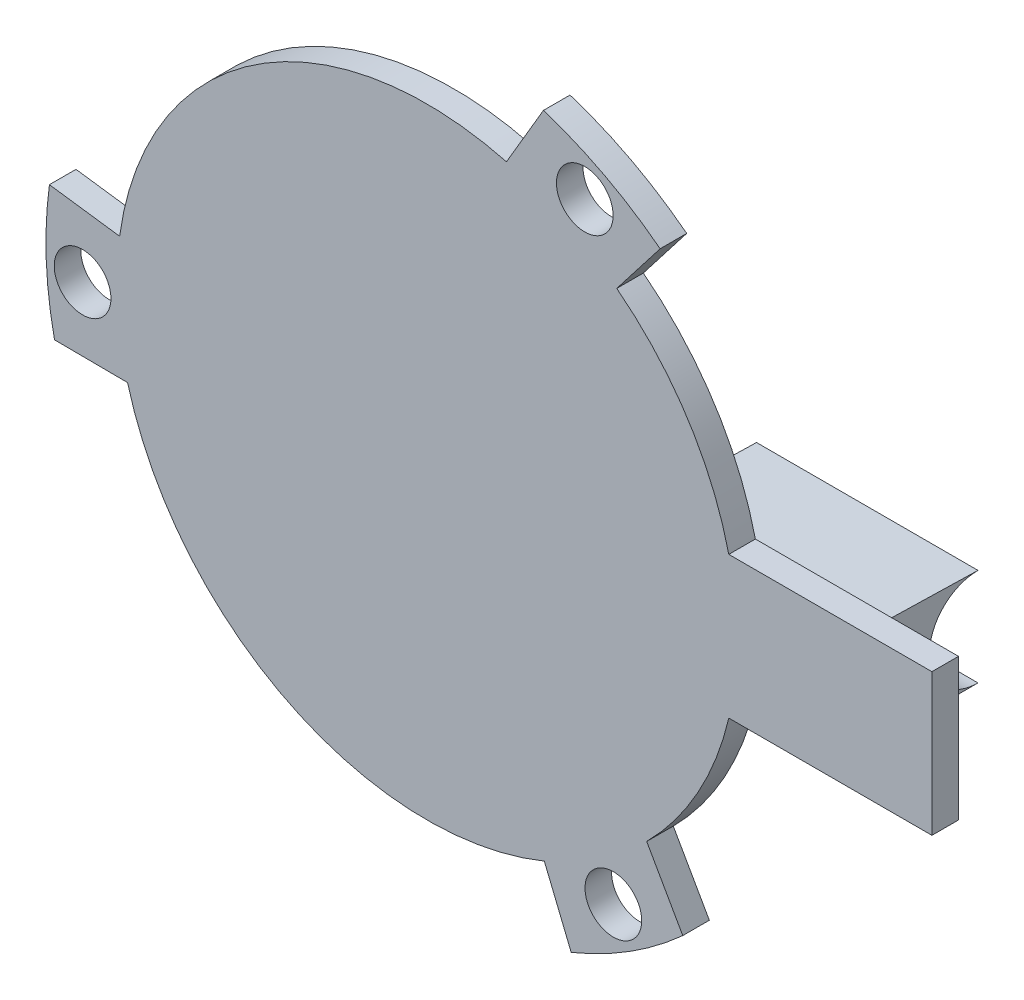
from build123d import *

# Parameters (mm, degrees)
SKETCH1_R           = 1.6
BOSS_EXTRUDE1_DEPTH = 1.5
BOSS_EXTRUDE2_START = -4.9
BOSS_EXTRUDE2_DEPTH = 12.5


with BuildPart() as part:
    # Sketch1 → Boss-Extrude1 (new body)
    with BuildSketch(Plane.XY):
        with BuildLine():
            Line((-17.340213643, 2.359447139), (-21.303691048, 2.898749343))
            ThreePointArc((-21.303691048, 2.898749343), (-21.483854857, -0.833054911), (-21.015258676, -4.539702939))
            Line((-21.015258676, -4.539702939), (-16.893017252, -4.569022665))
            ThreePointArc((-16.893017252, -4.569022665), (-17.46366078, -1.127187719), (-17.340213643, 2.359447139))
        make_face()
        with Locations((-19.431785099, -0.930778688)):
            Circle(SKETCH1_R, mode=Mode.SUBTRACT)
        with BuildLine():
            ThreePointArc((-16.893017252, -4.569022665), (-7.75565719, -15.687567738), (6.62676566, -16.196789092))
            ThreePointArc((6.62676566, -16.196789092), (9.70800359, -14.560380019), (12.403398325, -12.345270754))
            ThreePointArc((12.403398325, -12.345270754), (15.300036009, -8.494639375), (17.036725037, -4))
            Line((17.036725037, -4), (28.5, -4))
            Line((28.5, -4), (28.5, 4))
            Line((28.5, 4), (17.036725037, 4))
            ThreePointArc((17.036725037, 4), (14.721119178, 9.462486468), (10.713447983, 13.837341952))
            ThreePointArc((10.713447983, 13.837341952), (7.75565719, 15.687567738), (4.489618927, 16.91429342))
            ThreePointArc((4.489618927, 16.91429342), (-9.70800359, 14.560380019), (-17.340213643, 2.359447139))
            ThreePointArc((-17.340213643, 2.359447139), (-17.46366078, -1.127187719), (-16.893017252, -4.569022665))
        make_face()
        with BuildLine():
            Line((10.713447983, 13.837341952), (13.162236094, 17.00016297))
            ThreePointArc((13.162236094, 17.00016297), (10.020480713, 19.022091533), (6.576131268, 20.46959935))
            Line((6.576131268, 20.46959935), (4.489618927, 16.91429342))
            ThreePointArc((4.489618927, 16.91429342), (7.75565719, 15.687567738), (10.713447983, 13.837341952))
        make_face()
        with Locations((8.909814561, 17.293808881)):
            Circle(SKETCH1_R, mode=Mode.SUBTRACT)
        with BuildLine():
            Line((6.62676566, -16.196789092), (8.141454954, -19.898912313))
            ThreePointArc((8.141454954, -19.898912313), (11.463374144, -18.189036622), (14.439127409, -15.929896411))
            Line((14.439127409, -15.929896411), (12.403398325, -12.345270754))
            ThreePointArc((12.403398325, -12.345270754), (9.70800359, -14.560380019), (6.62676566, -16.196789092))
        make_face()
        with Locations((10.521970538, -16.363030193)):
            Circle(SKETCH1_R, mode=Mode.SUBTRACT)
    extrude(amount=BOSS_EXTRUDE1_DEPTH)

    # Sketch2 → Boss-Extrude2 (add)
    with BuildSketch(Plane(origin=(28.5, 0, 0), x_dir=(0, 0, -1), z_dir=(1, 0, 0)).offset(BOSS_EXTRUDE2_START)):
        with BuildLine():
            ThreePointArc((6, -2.75), (3.25, 0), (6, 2.75))
            Line((6, 2.75), (0, 2.898749343))
            Line((0, 2.898749343), (0, -2.752957148))
            Line((0, -2.752957148), (6, -2.75))
        make_face()
    extrude(amount=-BOSS_EXTRUDE2_DEPTH)


solid = part.part
